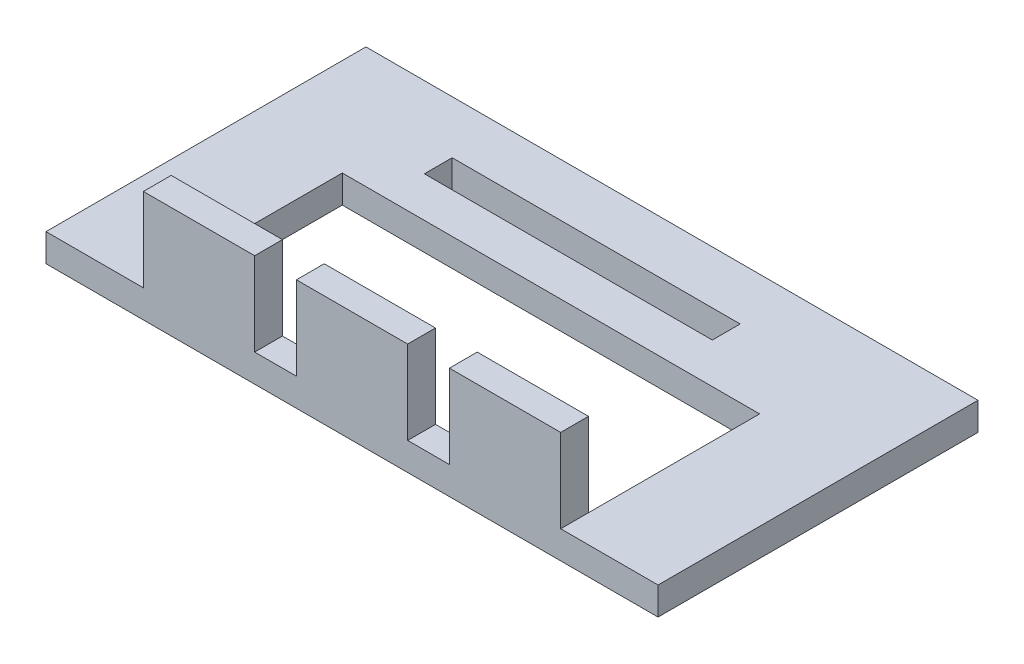
from build123d import *

# Parameters (mm, degrees)
SKETCH1_W           = 44
SKETCH1_H           = 23
BOSS_EXTRUDE1_DEPTH = 2
SKETCH2_W           = 20.7
SKETCH2_H           = 2
SKETCH2_W_2         = 30
SKETCH2_H_2         = 12.3
CUT_EXTRUDE1_DEPTH  = 2
SKETCH3_W           = 8
SKETCH3_H           = 2
BOSS_EXTRUDE2_DEPTH = 6


with BuildPart() as part:
    # Sketch1 → Boss-Extrude1 (new body)
    with BuildSketch(Plane(origin=(0, 0, 0), x_dir=(1, 0, 0), z_dir=(0, 1, 0))):
        Rectangle(SKETCH1_W, SKETCH1_H)
    extrude(amount=BOSS_EXTRUDE1_DEPTH)

    # Sketch2 → Cut-Extrude1 (cut)
    with BuildSketch(Plane(origin=(0, 2, 0), x_dir=(1, 0, 0), z_dir=(0, 1, 0))):
        with Locations((-1.65, 6.7)):
            Rectangle(SKETCH2_W, SKETCH2_H)
        with Locations((0, -3.35)):
            Rectangle(SKETCH2_W_2, SKETCH2_H_2)
    extrude(amount=-CUT_EXTRUDE1_DEPTH, mode=Mode.SUBTRACT)

    # Sketch3 → Boss-Extrude2 (add)
    with BuildSketch(Plane(origin=(0, 2, 0), x_dir=(1, 0, 0), z_dir=(0, 1, 0))):
        with Locations((-11, -10.5)):
            Rectangle(SKETCH3_W, SKETCH3_H)
        with Locations((0, -10.5)):
            Rectangle(SKETCH3_W, SKETCH3_H)
        with Locations((11, -10.5)):
            Rectangle(SKETCH3_W, SKETCH3_H)
    extrude(amount=BOSS_EXTRUDE2_DEPTH)


solid = part.part
